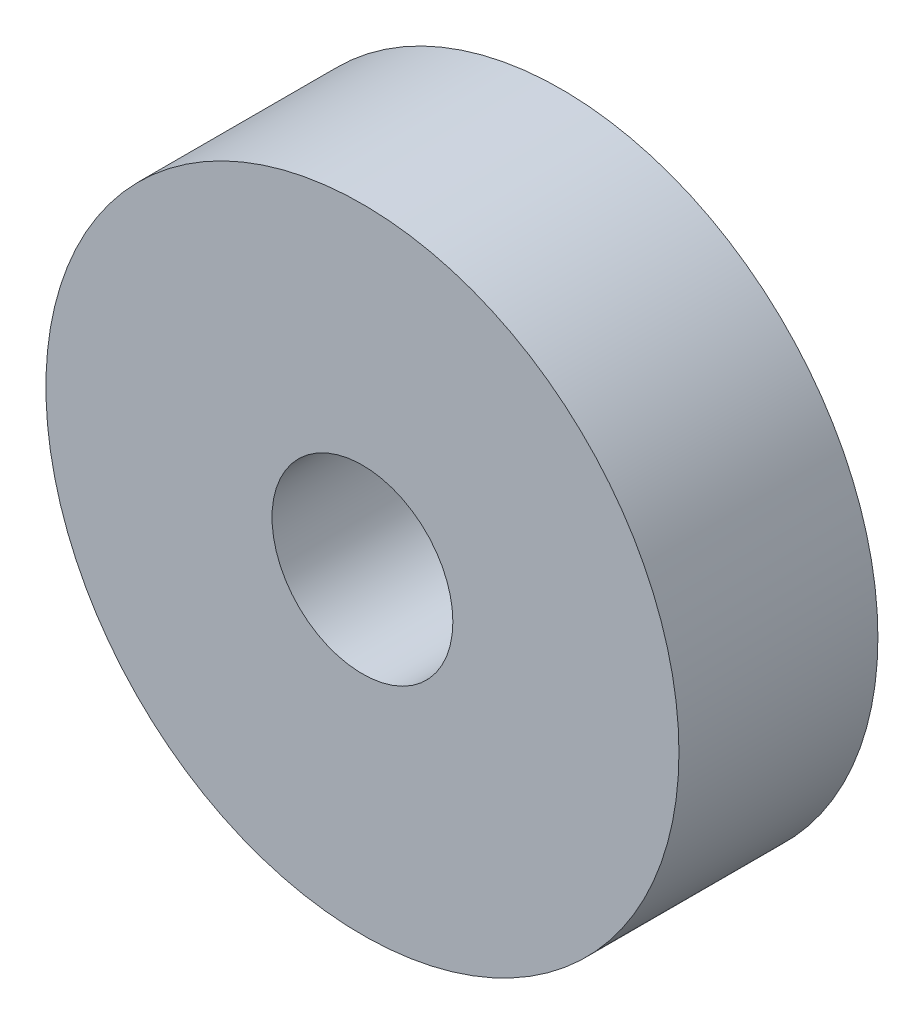
from build123d import *

# Parameters (mm, degrees)
CROQUIS1_R              = 17.5
CROQUIS1_R_2            = 5
SALIENTE_EXTRUIR1_DEPTH = 11


with BuildPart() as part:
    # Croquis1 → Saliente-Extruir1 (new body)
    with BuildSketch(Plane.XY):
        Circle(CROQUIS1_R)
        Circle(CROQUIS1_R_2, mode=Mode.SUBTRACT)
    extrude(amount=SALIENTE_EXTRUIR1_DEPTH)


solid = part.part
